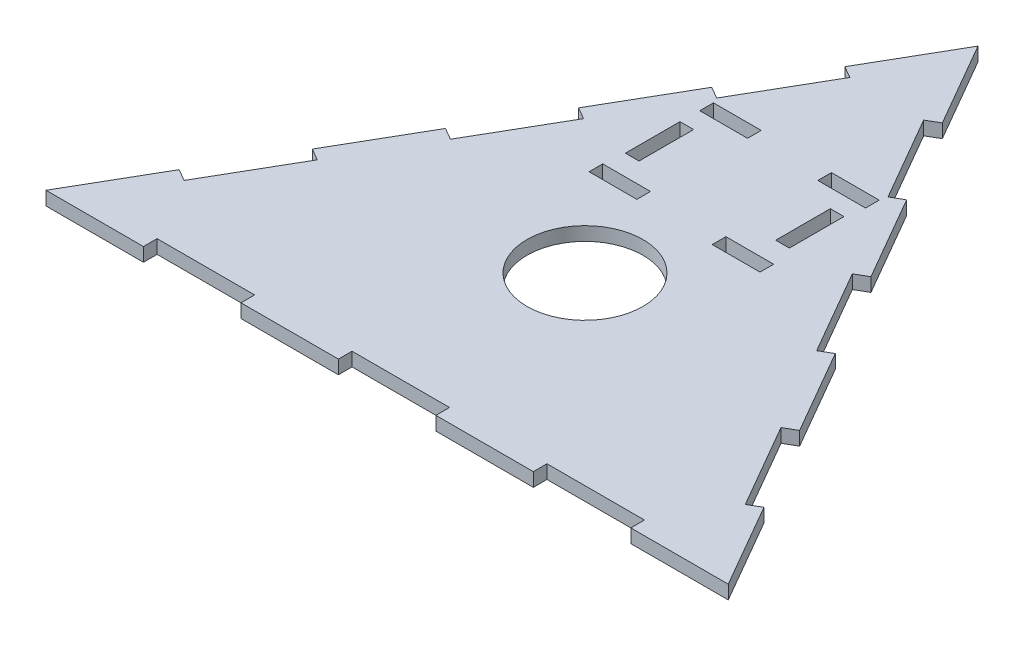
from build123d import *

# Parameters (mm, degrees)
BOSS_EXTRUDE1_DEPTH = 5.08
SKETCH2_W           = 36.285714285
SKETCH2_H           = 5.08
SKETCH2_W_2         = 36.285714286
CUT_EXTRUDE1_DEPTH  = 5.08
SKETCH3_W           = 36.285714285
SKETCH3_H           = 5.08
SKETCH3_W_2         = 36.285714286
CUT_EXTRUDE2_DEPTH  = 5.08
SKETCH4_W           = 36.285714285
SKETCH4_H           = 5.08
SKETCH4_W_2         = 36.285714286
CUT_EXTRUDE3_DEPTH  = 5.08
SKETCH5_R           = 21.59
CUT_EXTRUDE4_DEPTH  = 5.08
SKETCH6_W           = 17.78
SKETCH6_H           = 5.08
SKETCH6_W_2         = 5.08
SKETCH6_H_2         = 20.32
CUT_EXTRUDE5_DEPTH  = 11.16


with BuildPart() as part:
    # Sketch1 → Boss-Extrude1 (new body)
    with BuildSketch(Plane(origin=(0, 0, 0), x_dir=(1, 0, 0), z_dir=(0, 1, 0))):
        Polygon((0, 0), (-254, 0), (-127, 219.970452561), align=None)
    extrude(amount=BOSS_EXTRUDE1_DEPTH)

    # Sketch2 → Cut-Extrude1 (cut)
    with BuildSketch(Plane(origin=(0, 0, 0), x_dir=(-0.5, 0, -0.866025404), z_dir=(0.866025404, 0, -0.5))):
        with Locations((199.571428572, 2.54)):
            Rectangle(SKETCH2_W, SKETCH2_H)
        with Locations((127, 2.54)):
            Rectangle(SKETCH2_W_2, SKETCH2_H)
        with Locations((54.428571428, 2.54)):
            Rectangle(SKETCH2_W, SKETCH2_H)
    extrude(amount=-CUT_EXTRUDE1_DEPTH, mode=Mode.SUBTRACT)

    # Sketch3 → Cut-Extrude2 (cut)
    with BuildSketch(Plane(origin=(-190.5, 0, -109.985226281), x_dir=(-0.5, 0, 0.866025404), z_dir=(-0.866025404, 0, -0.5))):
        with Locations((-72.571428572, 2.54)):
            Rectangle(SKETCH3_W, SKETCH3_H)
        with Locations((0, 2.54)):
            Rectangle(SKETCH3_W_2, SKETCH3_H)
        with Locations((72.571428572, 2.54)):
            Rectangle(SKETCH3_W, SKETCH3_H)
    extrude(amount=-CUT_EXTRUDE2_DEPTH, mode=Mode.SUBTRACT)

    # Sketch4 → Cut-Extrude3 (cut)
    with BuildSketch(Plane.XY):
        with Locations((-199.571428572, 2.54)):
            Rectangle(SKETCH4_W, SKETCH4_H)
        with Locations((-127, 2.54)):
            Rectangle(SKETCH4_W_2, SKETCH4_H)
        with Locations((-54.428571428, 2.54)):
            Rectangle(SKETCH4_W, SKETCH4_H)
    extrude(amount=-CUT_EXTRUDE3_DEPTH, mode=Mode.SUBTRACT)

    # Sketch5 → Cut-Extrude4 (cut)
    with BuildSketch(Plane(origin=(0, 5.08, 0), x_dir=(1, 0, 0), z_dir=(0, 1, 0))):
        with Locations((-127, 73.66)):
            Circle(SKETCH5_R)
    extrude(amount=-CUT_EXTRUDE4_DEPTH, mode=Mode.SUBTRACT)

    # Sketch6 → Cut-Extrude5 (cut, through all)
    with BuildSketch(Plane(origin=(0, 10.16, 0), x_dir=(1, 0, 0), z_dir=(0, 1, 0))):
        with Locations((-149.055874493, 149.882969593)):
            Rectangle(SKETCH6_W, SKETCH6_H)
        with Locations((-104.605874493, 149.36329839)):
            Rectangle(SKETCH6_W, SKETCH6_H)
        with Locations((-99.525874493, 129.889965056)):
            Rectangle(SKETCH6_W_2, SKETCH6_H_2)
        with Locations((-103.592773819, 109.0579774)):
            Rectangle(SKETCH6_W, SKETCH6_H)
        with Locations((-149.987461319, 109.600384218)):
            Rectangle(SKETCH6_W, SKETCH6_H)
        with Locations((-155.572009554, 129.965942855)):
            Rectangle(SKETCH6_W_2, SKETCH6_H_2)
    extrude(amount=-CUT_EXTRUDE5_DEPTH, mode=Mode.SUBTRACT)


solid = part.part
